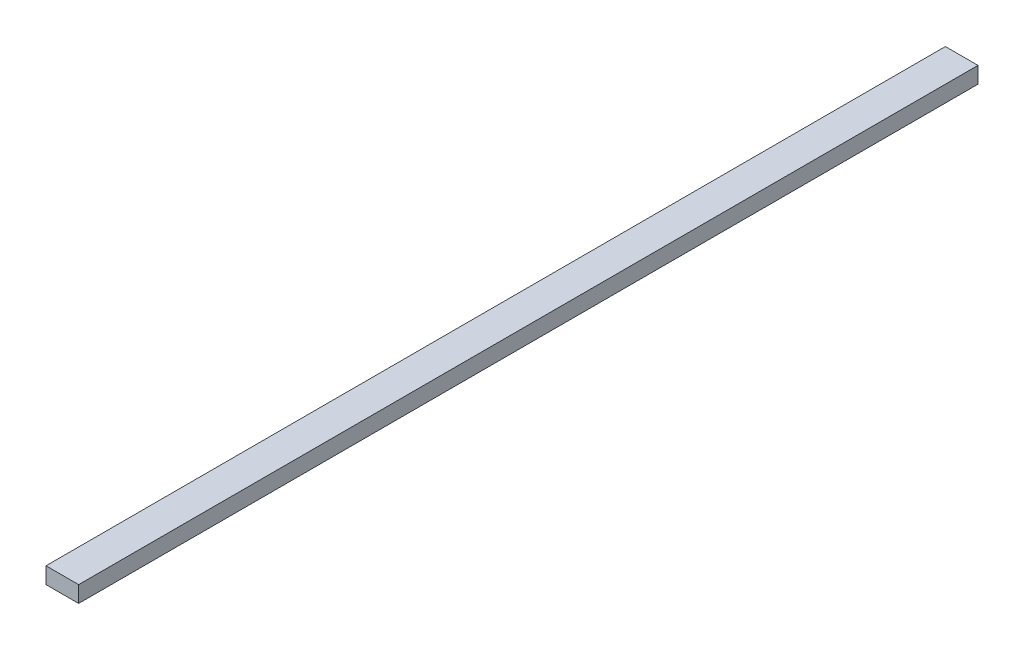
from build123d import *

# Parameters (mm, degrees)
CROQUIS1_W              = 25.4
CROQUIS1_H              = 12.7
SALIENTE_EXTRUIR1_DEPTH = 700


with BuildPart() as part:
    # Croquis1 → Saliente-Extruir1 (new body)
    with BuildSketch(Plane.XY):
        Rectangle(CROQUIS1_W, CROQUIS1_H)
    extrude(amount=-SALIENTE_EXTRUIR1_DEPTH)


solid = part.part
